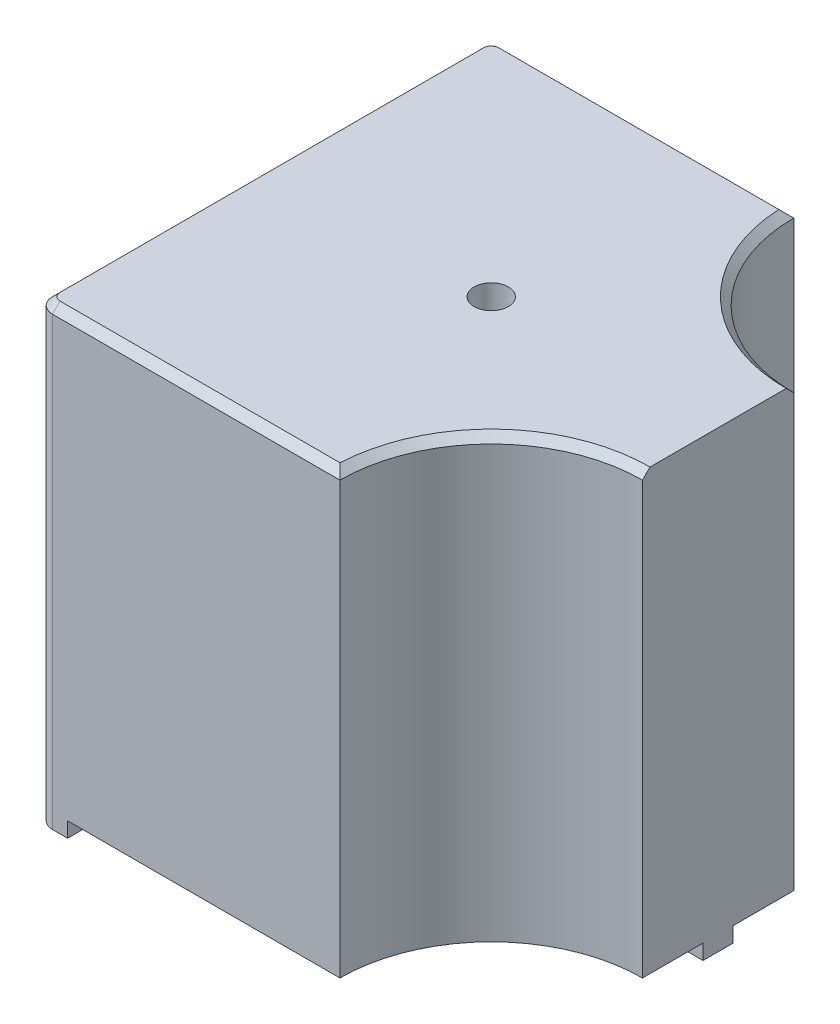
from build123d import *

# Parameters (mm, degrees)
SKETCH1_W                 = 30
SKETCH1_H                 = 30
BOSS_EXTRUDE1_DEPTH       = 30
CUT_EXTRUDE1_START        = -31
CUT_EXTRUDE1_DEPTH        = 32
SKETCH3_OUTSIDE_W         = 42.392
SKETCH3_OUTSIDE_H         = 42.392
SKETCH3_OUTSIDE_W_2       = 2
SKETCH3_OUTSIDE_H_2       = 2
CUT_EXTRUDE2_DEPTH        = 1
F_8_32_TAPPED_HOLE1_D     = 3.4544
F_8_32_TAPPED_HOLE1_DEPTH = 10.7188
F_8_32_TAPPED_HOLE1_TIP   = 1.037806461
F_4_40_TAPPED_HOLE1_D     = 2.2606
F_4_40_TAPPED_HOLE1_DEPTH = 7.5946
F_4_40_TAPPED_HOLE1_TIP   = 0.679152758
FILLET1_R                 = 1.000000032
CHAMFER1_SIZE             = 0.5


with BuildPart() as part:
    # Sketch1 → Boss-Extrude1 (new body)
    with BuildSketch(Plane(origin=(0, 0, 0), x_dir=(1, 0, 0), z_dir=(0, 1, 0))):
        Rectangle(SKETCH1_W, SKETCH1_H)
    extrude(amount=BOSS_EXTRUDE1_DEPTH)

    # Sketch2 → Cut-Extrude1 (cut)
    with BuildSketch(Plane(origin=(0, 30, 0), x_dir=(1, 0, 0), z_dir=(0, 1, 0)).offset(CUT_EXTRUDE1_START)):
        with BuildLine():
            Line((97.111025509, 5), (15, 5))
            ThreePointArc((15, 5), (7.928932188, 7.928932188), (5, 15))
            Line((5, 15), (5, 97.111025509))
            Line((5, 97.111025509), (121.122525896, 213.233551405))
            Line((121.122525896, 213.233551405), (213.233551405, 121.122525896))
            Line((213.233551405, 121.122525896), (97.111025509, 5))
        make_face()
    cut_extrude1 = extrude(amount=CUT_EXTRUDE1_DEPTH, mode=Mode.SUBTRACT)

    # Mirror1: Cut-Extrude1 across plane
    add(cut_extrude1.mirror(Plane.XY), mode=Mode.SUBTRACT)

    # Sketch3 outside → Cut-Extrude2 (cut)
    with BuildSketch(Plane.XZ):
        Rectangle(SKETCH3_OUTSIDE_W, SKETCH3_OUTSIDE_H)
        with Locations((-14, 14)):
            Rectangle(SKETCH3_OUTSIDE_W_2, SKETCH3_OUTSIDE_H_2, mode=Mode.SUBTRACT)
        with Locations((-14, -14)):
            Rectangle(SKETCH3_OUTSIDE_W_2, SKETCH3_OUTSIDE_H_2, mode=Mode.SUBTRACT)
        with Locations((14, 0)):
            Rectangle(SKETCH3_OUTSIDE_W_2, SKETCH3_OUTSIDE_H_2, mode=Mode.SUBTRACT)
    extrude(amount=-CUT_EXTRUDE2_DEPTH, mode=Mode.SUBTRACT)

    # #8-32 Tapped Hole1
    with Locations(Plane.XZ.offset(-1)):
        with Locations((0, 0)):
            Hole(F_8_32_TAPPED_HOLE1_D / 2, depth=F_8_32_TAPPED_HOLE1_DEPTH)
            with Locations((0, 0, -(F_8_32_TAPPED_HOLE1_DEPTH + F_8_32_TAPPED_HOLE1_TIP / 2))):  # 118° drill point
                Cone(0, F_8_32_TAPPED_HOLE1_D / 2, F_8_32_TAPPED_HOLE1_TIP, mode=Mode.SUBTRACT)

    # #4-40 Tapped Hole1
    with Locations(Plane(origin=(0, 30, 0), x_dir=(-1, 0, 0), z_dir=(0, 1, 0))):
        with Locations((0, 0)):
            Hole(F_4_40_TAPPED_HOLE1_D / 2, depth=F_4_40_TAPPED_HOLE1_DEPTH)
            with Locations((0, 0, -(F_4_40_TAPPED_HOLE1_DEPTH + F_4_40_TAPPED_HOLE1_TIP / 2))):  # 118° drill point
                Cone(0, F_4_40_TAPPED_HOLE1_D / 2, F_4_40_TAPPED_HOLE1_TIP, mode=Mode.SUBTRACT)

    # Fillet1
    fillet1_edges = [part.edges().sort_by_distance(p)[0] for p in [
        (-15, 15, 15),
        (-15, 15, -15),
    ]]
    fillet(fillet1_edges, radius=FILLET1_R)

    # Chamfer1
    chamfer1_edges = [part.edges().sort_by_distance(p)[0] for p in [
        (-14.707106772, 30, -14.707106772),
        (-14.707106772, 30, 14.707106772),
        (-4.499999984, 30, -15),
        (7.928932188, 30, -7.928932188),
        (7.928932188, 30, 7.928932188),
        (-4.499999984, 30, 15),
        (-15, 30, 0),
    ]]
    chamfer(chamfer1_edges, length=CHAMFER1_SIZE)


solid = part.part
